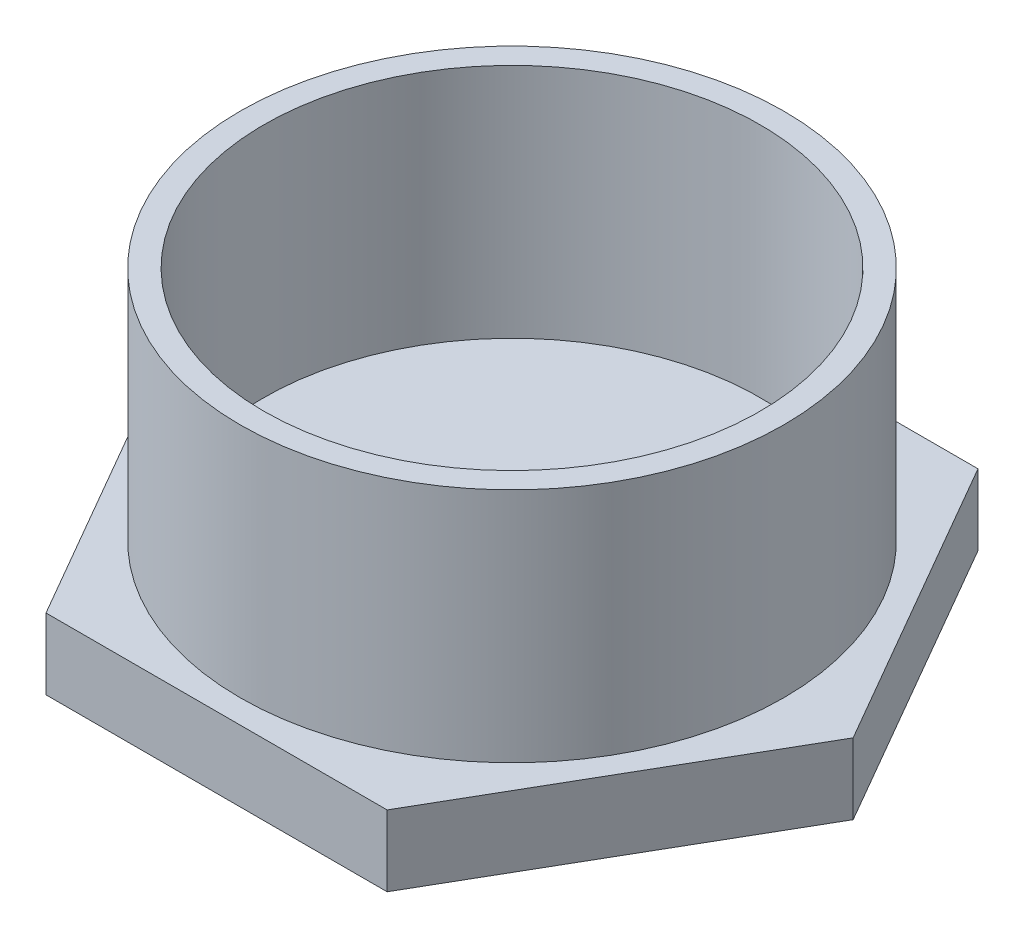
from build123d import *

# Parameters (mm, degrees)
BOSS_EXTRUDE1_DEPTH = 3
SKETCH2_R           = 11.5
BOSS_EXTRUDE2_DEPTH = 10
SKETCH3_R           = 10.5
CUT_EXTRUDE1_DEPTH  = 10


with BuildPart() as part:
    # Sketch1 → Boss-Extrude1 (new body)
    with BuildSketch(Plane(origin=(0, 0, 0), x_dir=(1, 0, 0), z_dir=(0, 1, 0))):
        Polygon((7.216878365, -12.5), (14.43375673, 0), (7.216878365, 12.5), (-7.216878365, 12.5), (-14.43375673, 0), (-7.216878365, -12.5), align=None)
    extrude(amount=BOSS_EXTRUDE1_DEPTH)

    # Sketch2 → Boss-Extrude2 (add)
    with BuildSketch(Plane(origin=(0, 3, 0), x_dir=(1, 0, 0), z_dir=(0, 1, 0))):
        Circle(SKETCH2_R)
    extrude(amount=BOSS_EXTRUDE2_DEPTH)

    # Sketch3 → Cut-Extrude1 (cut)
    with BuildSketch(Plane(origin=(0, 13, 0), x_dir=(1, 0, 0), z_dir=(0, 1, 0))):
        Circle(SKETCH3_R)
    extrude(amount=-CUT_EXTRUDE1_DEPTH, mode=Mode.SUBTRACT)


solid = part.part
